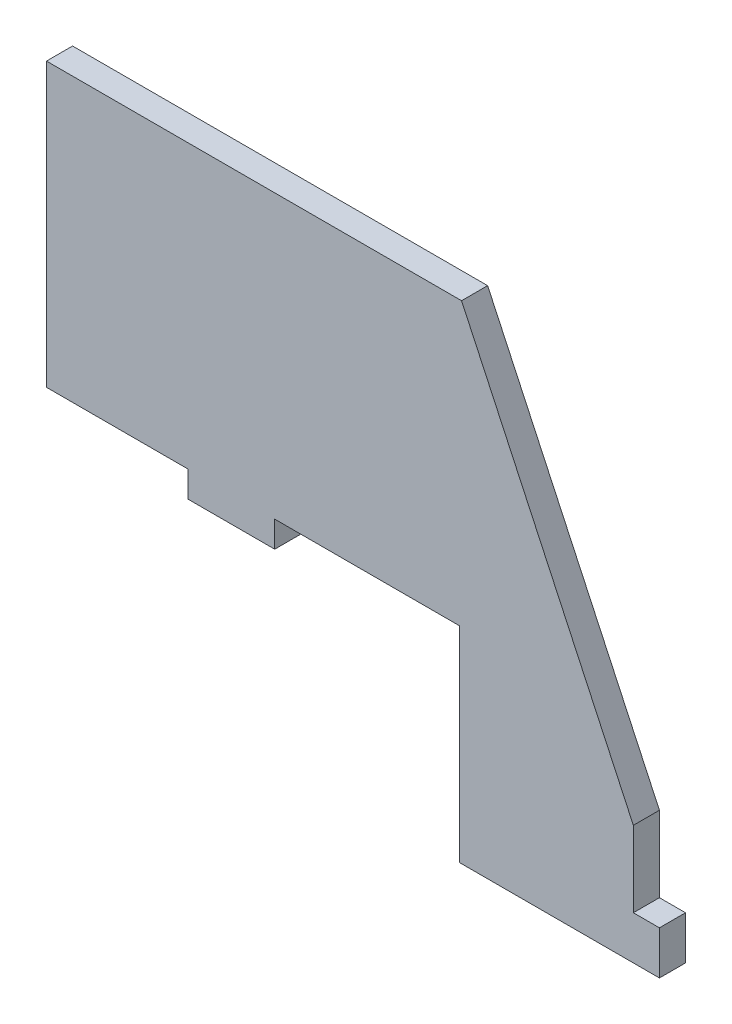
from build123d import *

# Parameters (mm, degrees)
ESQUISSE1_W             = 135
ESQUISSE1_H             = 112.17
BOSS_EXTRU_1_DEPTH      = 6
ENL_V_MAT_EXTRU_1_DEPTH = 6
ESQUISSE3_W             = 6
ESQUISSE3_H             = 10
ESQUISSE3_W_2           = 20
ESQUISSE3_H_2           = 6
BOSS_EXTRU_2_DEPTH      = 6


with BuildPart() as part:
    # Esquisse1 → Boss.-Extru.1 (new body)
    with BuildSketch(Plane.XY):
        Rectangle(ESQUISSE1_W, ESQUISSE1_H)
    extrude(amount=BOSS_EXTRU_1_DEPTH)

    # Esquisse2 → Enlèv. mat.-Extru.1 (cut)
    with BuildSketch(Plane.XY.offset(6)):
        Polygon((27.5, -56.085), (-67.5, -56.085), (-67.5, -8.915), (-38.5, -8.915), (27.5, -8.915), align=None)
        Polygon((67.5, -28.665), (27.980425971, 56.085), (67.5, 56.085), align=None)
    extrude(amount=-ENL_V_MAT_EXTRU_1_DEPTH, mode=Mode.SUBTRACT)

    # Esquisse3 → Boss.-Extru.2 (add)
    with BuildSketch(Plane.XY.offset(6)):
        with Locations((70.5, -51.085)):
            Rectangle(ESQUISSE3_W, ESQUISSE3_H)
        with Locations((-25, -11.915)):
            Rectangle(ESQUISSE3_W_2, ESQUISSE3_H_2)
    extrude(amount=-BOSS_EXTRU_2_DEPTH)


solid = part.part
